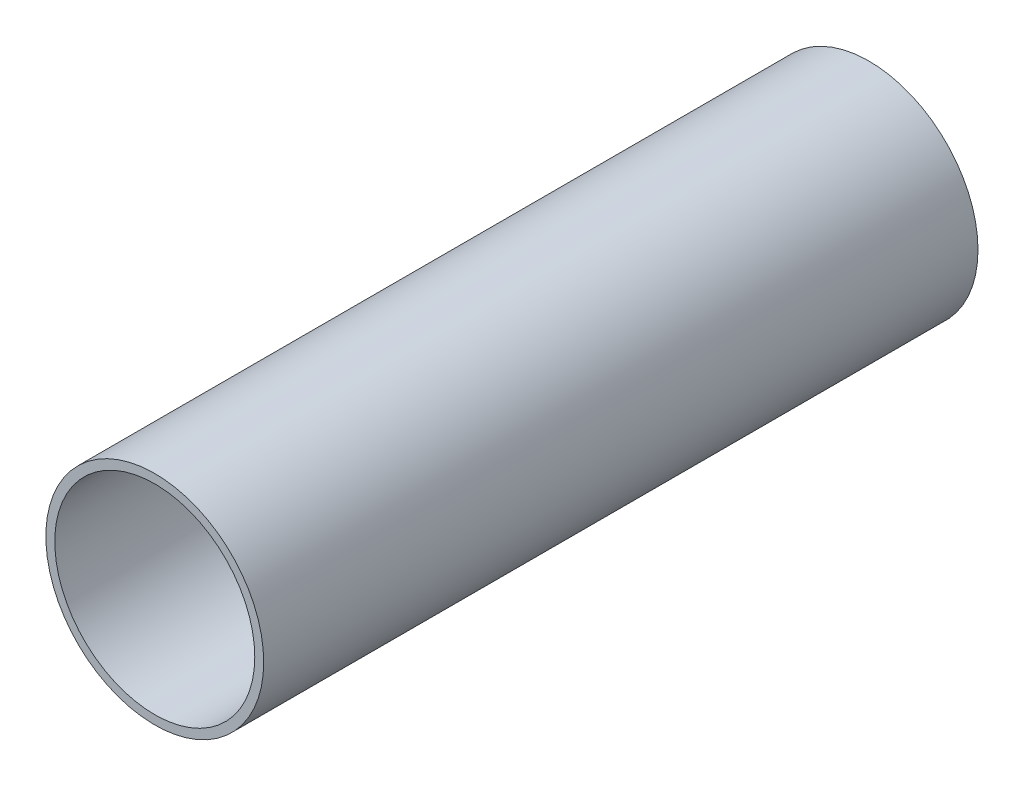
from build123d import *

# Parameters (mm, degrees)
SKETCH_1_R      = 15.25
SKETCH_1_R_2    = 14
EXTRUDE_1_DEPTH = 50


with BuildPart() as part:
    # 草图1 → 凸台-拉伸1 (new body, symmetric)
    with BuildSketch(Plane.XY):
        Circle(SKETCH_1_R)
        Circle(SKETCH_1_R_2, mode=Mode.SUBTRACT)
    extrude(amount=EXTRUDE_1_DEPTH, both=True)


solid = part.part
